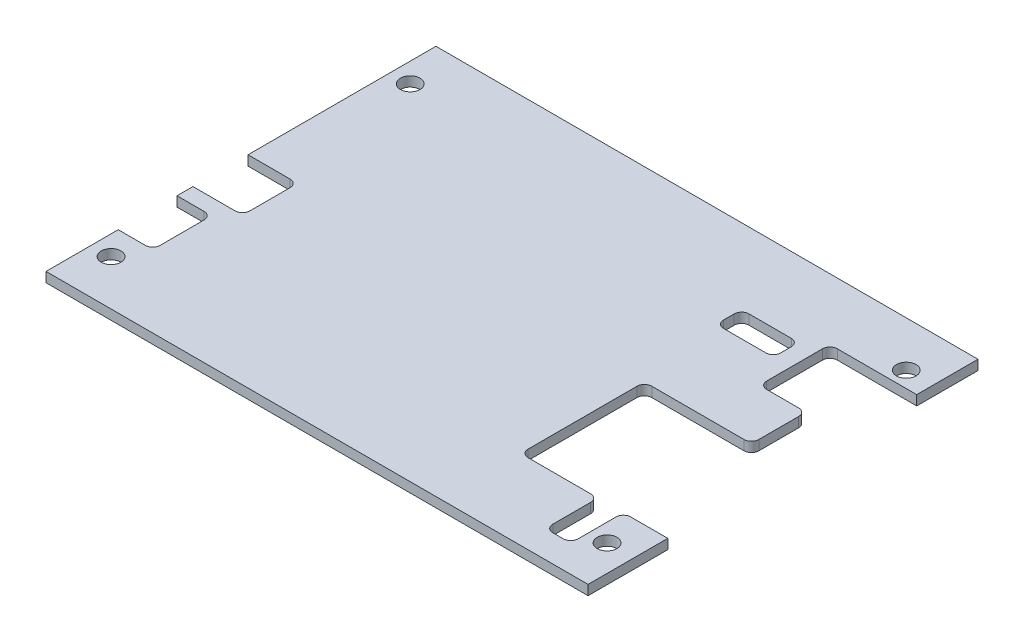
from build123d import *

# Parameters (mm, degrees)
SKETCH1_R           = 1.5875
BOSS_EXTRUDE1_DEPTH = 1.5875


with BuildPart() as part:
    # Sketch1 → Boss-Extrude1 (new body)
    with BuildSketch(Plane(origin=(0, 0, 0), x_dir=(1, 0, 0), z_dir=(0, 1, 0))):
        with BuildLine():
            Line((96.867912936, 16.100919196), (90.894787936, 16.100919196))
            ThreePointArc((90.894787936, 16.100919196), (90.052888924, 15.752193207), (89.704162936, 14.910294196))
            Line((89.704162936, 14.910294196), (89.704162936, 8.798419196))
            ThreePointArc((89.704162936, 8.798419196), (89.355436947, 7.956520185), (88.513537936, 7.607794196))
            Line((88.513537936, 7.607794196), (86.807287936, 7.607794196))
            ThreePointArc((86.807287936, 7.607794196), (85.965388924, 7.956520185), (85.616662936, 8.798419196))
            Line((85.616662936, 8.798419196), (85.616662936, 14.910294196))
            ThreePointArc((85.616662936, 14.910294196), (85.267936947, 15.752193207), (84.426037936, 16.100919196))
            Line((84.426037936, 16.100919196), (74.325412936, 16.100919196))
            ThreePointArc((74.325412936, 16.100919196), (73.483513924, 16.449645185), (73.134787936, 17.291544196))
            Line((73.134787936, 17.291544196), (73.134787936, 34.868344196))
            ThreePointArc((73.134787936, 34.868344196), (73.483513924, 35.710243207), (74.325412936, 36.058969196))
            Line((74.325412936, 36.058969196), (89.210056936, 36.058969196))
            ThreePointArc((89.210056936, 36.058969196), (90.051955947, 36.407695185), (90.400681936, 37.249594196))
            Line((90.400681936, 37.249594196), (90.400681936, 43.684176196))
            ThreePointArc((90.400681936, 43.684176196), (90.051955947, 44.526075207), (89.210056936, 44.874801196))
            Line((89.210056936, 44.874801196), (84.055412936, 44.874801196))
            ThreePointArc((84.055412936, 44.874801196), (83.213513924, 45.223527185), (82.864787936, 46.065426196))
            Line((82.864787936, 46.065426196), (82.864787936, 55.065426196))
            ThreePointArc((82.864787936, 55.065426196), (83.213513924, 55.907325207), (84.055412936, 56.256051196))
            Line((84.055412936, 56.256051196), (96.867912936, 56.256051196))
            Line((96.867912936, 56.256051196), (96.867912936, 66.140544196))
            Line((96.867912936, 66.140544196), (9.428412936, 66.140544196))
            Line((9.428412936, 66.140544196), (9.428412936, 35.829099196))
            Line((9.428412936, 35.829099196), (16.226102936, 35.829099196))
            ThreePointArc((16.226102936, 35.829099196), (17.068001947, 35.480373207), (17.416727936, 34.638474196))
            Line((17.416727936, 34.638474196), (17.416727936, 28.138474196))
            ThreePointArc((17.416727936, 28.138474196), (17.068001947, 27.296575185), (16.226102936, 26.947849196))
            Line((16.226102936, 26.947849196), (9.428412936, 26.947849196))
            Line((9.428412936, 26.947849196), (9.428412936, 24.375238196))
            Line((9.428412936, 24.375238196), (13.802302936, 24.375238196))
            ThreePointArc((13.802302936, 24.375238196), (14.644201947, 24.026512207), (14.992927936, 23.184613196))
            Line((14.992927936, 23.184613196), (14.992927936, 16.081488196))
            ThreePointArc((14.992927936, 16.081488196), (14.644201947, 15.239589185), (13.802302936, 14.890863196))
            Line((13.802302936, 14.890863196), (9.428412936, 14.890863196))
            Line((9.428412936, 14.890863196), (9.428412936, 3.240544196))
            Line((9.428412936, 3.240544196), (96.867912936, 3.240544196))
            Line((96.867912936, 3.240544196), (96.867912936, 16.100919196))
        make_face()
        with Locations((92.613412936, 58.820544196)):
            Circle(SKETCH1_R, mode=Mode.SUBTRACT)
        with Locations((12.603412936, 10.560544196)):
            Circle(SKETCH1_R, mode=Mode.SUBTRACT)
        with Locations((92.613412936, 10.560544196)):
            Circle(SKETCH1_R, mode=Mode.SUBTRACT)
        with Locations((12.603412936, 58.820544196)):
            Circle(SKETCH1_R, mode=Mode.SUBTRACT)
        with BuildLine():
            Line((78.881537936, 49.918794196), (72.055287936, 49.918794196))
            ThreePointArc((72.055287936, 49.918794196), (71.213388924, 50.267520185), (70.864662936, 51.109419196))
            Line((70.864662936, 51.109419196), (70.864662936, 52.815669196))
            ThreePointArc((70.864662936, 52.815669196), (71.213388924, 53.657568207), (72.055287936, 54.006294196))
            Line((72.055287936, 54.006294196), (78.881537936, 54.006294196))
            ThreePointArc((78.881537936, 54.006294196), (79.723436947, 53.657568207), (80.072162936, 52.815669196))
            Line((80.072162936, 52.815669196), (80.072162936, 51.109419196))
            ThreePointArc((80.072162936, 51.109419196), (79.723436947, 50.267520185), (78.881537936, 49.918794196))
        make_face(mode=Mode.SUBTRACT)
    extrude(amount=BOSS_EXTRUDE1_DEPTH)


solid = part.part
